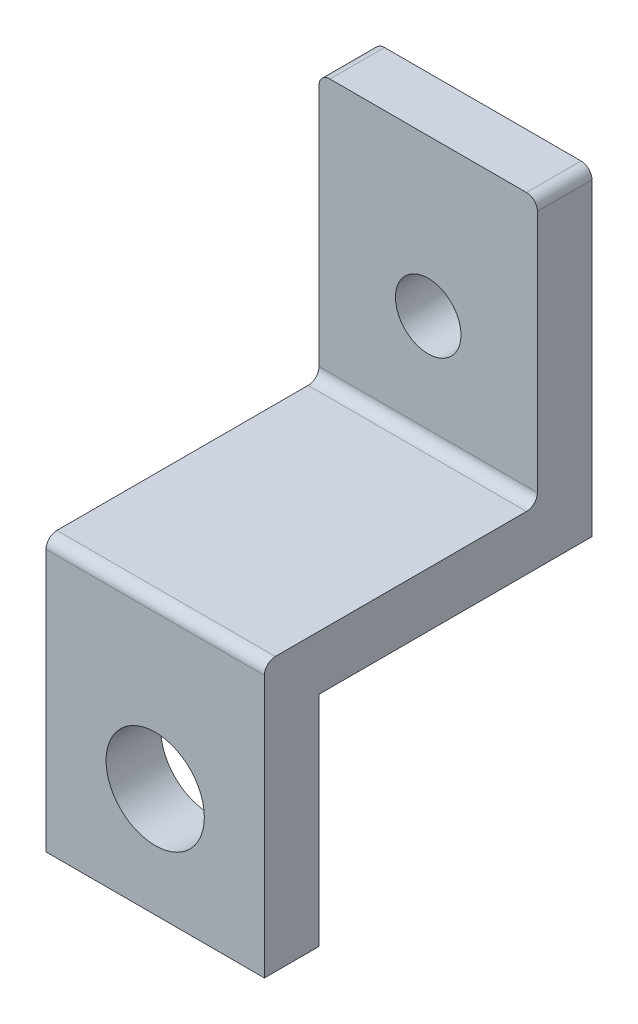
from build123d import *

# Parameters (mm, degrees)
SKETCH1_R           = 4.5
BOSS_EXTRUDE1_DEPTH = 5
SKETCH2_W           = 20
SKETCH2_H           = 29.3
BOSS_EXTRUDE2_DEPTH = 25
CUT_EXTRUDE1_DEPTH  = 30
SKETCH4_R           = 2.5
SKETCH4_R_2         = 3
CUT_EXTRUDE2_DEPTH  = 30
FILLET2_R           = 1


with BuildPart() as part:
    # Sketch1 → Boss-Extrude1 (new body)
    with BuildSketch(Plane.XY):
        Polygon((-10, 10), (-10, -10), (10, -10), (10, 10), (10, 39.3), (-10, 39.3), align=None)
        Circle(SKETCH1_R, mode=Mode.SUBTRACT)
    extrude(amount=BOSS_EXTRUDE1_DEPTH)

    # Sketch2 → Boss-Extrude2 (add)
    with BuildSketch(Plane(origin=(0, 0, 0), x_dir=(-1, 0, 0), z_dir=(0, 0, -1))):
        with Locations((0, 24.65)):
            Rectangle(SKETCH2_W, SKETCH2_H)
    extrude(amount=BOSS_EXTRUDE2_DEPTH)

    # Sketch3 → Cut-Extrude1 (cut)
    with BuildSketch(Plane(origin=(10, 0, 0), x_dir=(0, 0, -1), z_dir=(1, 0, 0))):
        Polygon((0, 15), (-5, 15), (-5, 39.3), (20, 39.3), (20, 15), align=None)
    extrude(amount=-CUT_EXTRUDE1_DEPTH, mode=Mode.SUBTRACT)

    # Sketch4 → Cut-Extrude2 (cut)
    with BuildSketch(Plane.XY.offset(-20)):
        with Locations((0, 45)):
            Circle(SKETCH4_R)
        with Locations((0, 25)):
            Circle(SKETCH4_R_2)
    extrude(amount=-CUT_EXTRUDE2_DEPTH, mode=Mode.SUBTRACT)

    # Fillet2
    fillet2_edges = [part.edges().sort_by_distance(p)[0] for p in [
        (-10, 39.3, -22.5),
        (10, 39.3, -22.5),
        (0, 15, -20),
        (0, 15, 5),
    ]]
    fillet(fillet2_edges, radius=FILLET2_R)


solid = part.part
